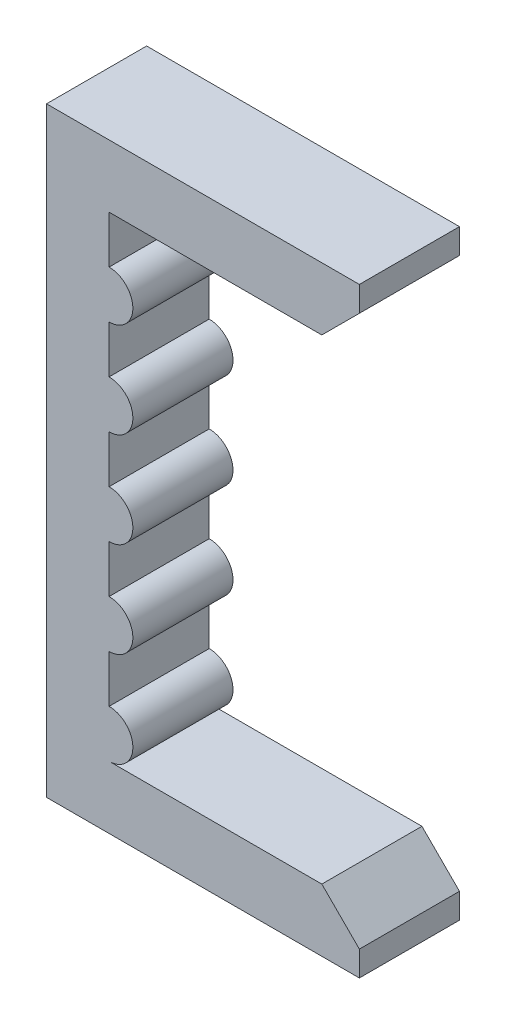
from build123d import *

# Parameters (mm, degrees)
BOSS_EXTRUDE1_DEPTH = 8
SKETCH1_3_R         = 1.9
BOSS_EXTRUDE2_DEPTH = 8
LPATTERN1_COUNT     = 5
LPATTERN1_PITCH     = 7.6
CHAMFER1_SIZE       = 3


with BuildPart() as part:
    # Sketch1 → Boss-Extrude1 (new body)
    with BuildSketch(Plane.XY):
        Polygon((0, 0), (0, 48), (25, 48), (25, 43), (5, 43), (5, 5), (25, 5), (25, 0), align=None)
    extrude(amount=BOSS_EXTRUDE1_DEPTH)

    # Sketch1_3 → Boss-Extrude2 (add)
    with BuildSketch(Plane.XY):
        with Locations((5, 6.9)):
            Circle(SKETCH1_3_R)
    boss_extrude2 = extrude(amount=BOSS_EXTRUDE2_DEPTH)

    # LPattern1: Boss-Extrude2 ×5
    with Locations(*[(0, i * LPATTERN1_PITCH, 0) for i in range(1, LPATTERN1_COUNT)]):
        add(boss_extrude2)

    # Chamfer1
    chamfer1_edges = [part.edges().sort_by_distance(p)[0] for p in [
        (25, 43, 4),
        (25, 5, 4),
    ]]
    chamfer(chamfer1_edges, length=CHAMFER1_SIZE)


solid = part.part
